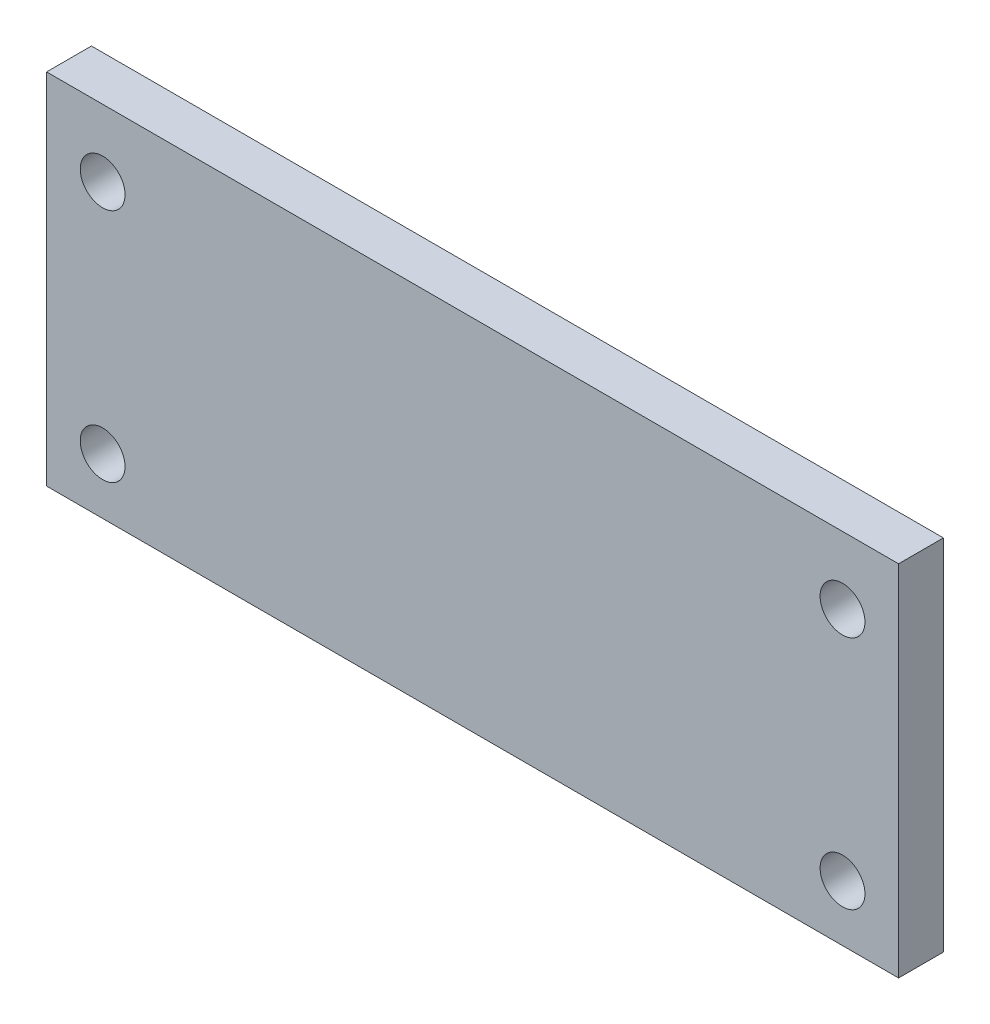
from build123d import *

# Parameters (mm, degrees)
SKETCH_1_W      = 76
SKETCH_1_H      = 32
SKETCH_1_R      = 2
EXTRUDE_1_DEPTH = 4


with BuildPart() as part:
    # Эскиз1 → Бобышка-Вытянуть1 (new body)
    with BuildSketch(Plane.XY):
        with Locations((38, 16)):
            Rectangle(SKETCH_1_W, SKETCH_1_H)
        with Locations((5, 5)):
            Circle(SKETCH_1_R, mode=Mode.SUBTRACT)
        with Locations((5, 26)):
            Circle(SKETCH_1_R, mode=Mode.SUBTRACT)
        with Locations((71, 26)):
            Circle(SKETCH_1_R, mode=Mode.SUBTRACT)
        with Locations((71, 5)):
            Circle(SKETCH_1_R, mode=Mode.SUBTRACT)
    extrude(amount=EXTRUDE_1_DEPTH)


solid = part.part
